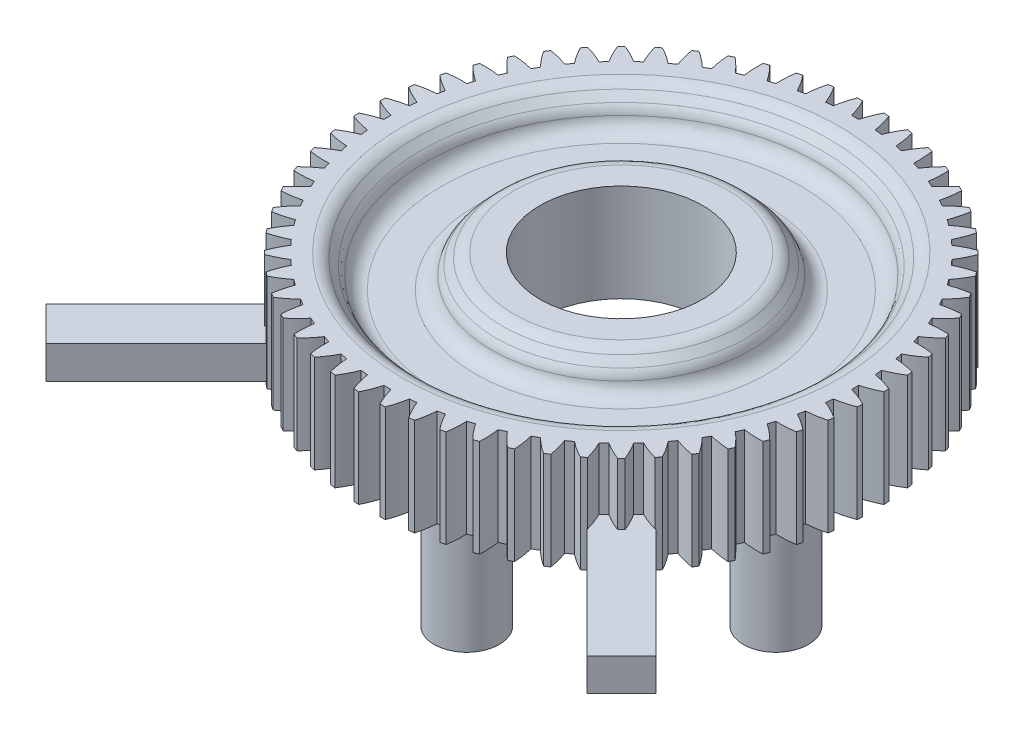
from build123d import *

# Parameters (mm, degrees)
BOSS_EXTRUDE1_DEPTH = 6
SKETCH2_R           = 5
CUT_EXTRUDE2_DEPTH  = 6
SKETCH3_R           = 12
SKETCH3_R_2         = 8
CUT_EXTRUDE3_DEPTH  = 2
CHAMFER1_SIZE       = 1
CHAMFER2_SIZE       = 1
FILLET1_R           = 1
FILLET2_R           = 1
FILLET3_R           = 1
FILLET4_R           = 1
SKETCH4_R           = 2
BOSS_EXTRUDE2_DEPTH = 9.12
FILLET5_R           = 1
FILLET6_R           = 1
SKETCH5_R           = 1.1
CUT_EXTRUDE4_DEPTH  = 8
SKETCH6_R           = 1.1
CUT_EXTRUDE5_DEPTH  = 8
SKETCH8_R           = 1.1
CUT_EXTRUDE6_DEPTH  = 8
SKETCH7_R           = 1.1
CUT_EXTRUDE7_DEPTH  = 8
SKETCH10_W          = 3
SKETCH10_H          = 2
BOSS_EXTRUDE3_DEPTH = 20
SKETCH11_W          = 3
SKETCH11_H          = 2
BOSS_EXTRUDE4_DEPTH = 20


with BuildPart() as part:
    # Sketch1 → Boss-Extrude1 (new body)
    with BuildSketch(Plane(origin=(0, 0, 0), x_dir=(1, 0, 0), z_dir=(0, 1, 0))):
        with BuildLine():
            ThreePointArc((-0.214919076, 14.372458517), (-0.404612151, 14.940310942), (-0.649952369, 15.486431825))
            ThreePointArc((-0.649952369, 15.486431825), (-0.811189587, 15.478823388), (-0.97233883, 15.469536266))
            ThreePointArc((-0.97233883, 15.469536266), (-1.159249871, 14.900762055), (-1.288547047, 14.316192059))
            ThreePointArc((-1.288547047, 14.316192059), (-1.502474396, 14.295323323), (-1.716065774, 14.27125803))
            ThreePointArc((-1.716065774, 14.27125803), (-1.964076433, 14.816171375), (-2.265157828, 15.333655514))
            ThreePointArc((-2.265157828, 15.333655514), (-2.424716474, 15.309234879), (-2.584012155, 15.28315395))
            ThreePointArc((-2.584012155, 15.28315395), (-2.710446184, 14.69795802), (-2.777930853, 14.103075124))
            ThreePointArc((-2.777930853, 14.103075124), (-2.988504909, 14.059959212), (-3.198410703, 14.013699372))
            ThreePointArc((-3.198410703, 14.013699372), (-3.502021688, 14.529703452), (-3.855545549, 15.012881184))
            ThreePointArc((-3.855545549, 15.012881184), (-4.011677465, 14.971915907), (-4.167374308, 14.929326919))
            ThreePointArc((-4.167374308, 14.929326919), (-4.231946087, 14.334120799), (-4.236878873, 13.735442665))
            ThreePointArc((-4.236878873, 13.735442665), (-4.441792543, 13.670551965), (-4.645712981, 13.602604411))
            ThreePointArc((-4.645712981, 13.602604411), (-5.001597866, 14.084045777), (-5.403690912, 14.527623304))
            ThreePointArc((-5.403690912, 14.527623304), (-5.554685483, 14.47056221), (-5.705077642, 14.411931778))
            ThreePointArc((-5.705077642, 14.411931778), (-5.707079709, 13.81323667), (-5.649406567, 13.217322541))
            ThreePointArc((-5.649406567, 13.217322541), (-5.846414773, 13.131368007), (-6.04211566, 13.042477188))
            ThreePointArc((-6.04211566, 13.042477188), (-6.446375297, 13.484081067), (-6.892632113, 13.883198462))
            ThreePointArc((-6.892632113, 13.883198462), (-7.036835011, 13.810666724), (-7.180274757, 13.736637214))
            ThreePointArc((-7.180274757, 13.736637214), (-7.119685177, 13.141012548), (-7.000037986, 12.554391384))
            ThreePointArc((-7.000037986, 12.554391384), (-7.186982265, 12.448314753), (-7.372319462, 12.339454574))
            ThreePointArc((-7.372319462, 12.339454574), (-7.820524697, 12.736382662), (-8.306055999, 13.086667111))
            ThreePointArc((-8.306055999, 13.086667111), (-8.441887308, 12.999459402), (-8.576803085, 12.910841898))
            ThreePointArc((-8.576803085, 12.910841898), (-8.45428569, 12.324813461), (-8.27397533, 11.753912406))
            ThreePointArc((-8.27397533, 11.753912406), (-8.448807482, 11.628875876), (-8.621750395, 11.501239032))
            ThreePointArc((-8.621750395, 11.501239032), (-9.108990598, 11.849142503), (-9.628476804, 12.146756216))
            ThreePointArc((-9.628476804, 12.146756216), (-9.754448327, 12.045828002), (-9.879361969, 11.943593414))
            ThreePointArc((-9.879361969, 11.943593414), (-9.696259085, 11.373581858), (-9.457261075, 10.824655824))
            ThreePointArc((-9.457261075, 10.824655824), (-9.618065601, 10.682029321), (-9.776719431, 10.537014227))
            ThreePointArc((-9.776719431, 10.537014227), (-10.297656297, 10.832081377), (-10.845405807, 11.073763636))
            ThreePointArc((-10.845405807, 11.073763636), (-10.960137374, 10.960220708), (-11.073680302, 10.845489141))
            ThreePointArc((-11.073680302, 10.845489141), (-10.831998043, 10.297739631), (-10.536930893, 9.776802765))
            ThreePointArc((-10.536930893, 9.776802765), (-10.681945987, 9.618148935), (-10.82457249, 9.457344409))
            ThreePointArc((-10.82457249, 9.457344409), (-11.373498524, 9.696342419), (-11.94351008, 9.879445303))
            ThreePointArc((-11.94351008, 9.879445303), (-12.045744668, 9.754531661), (-12.146672882, 9.628560137))
            ThreePointArc((-12.146672882, 9.628560137), (-11.849059169, 9.109073931), (-11.501155698, 8.621833728))
            ThreePointArc((-11.501155698, 8.621833728), (-11.628792543, 8.448890816), (-11.753829073, 8.274058664))
            ThreePointArc((-11.753829073, 8.274058664), (-12.324730128, 8.454369024), (-12.910758564, 8.576886419))
            ThreePointArc((-12.910758564, 8.576886419), (-12.999376069, 8.441970642), (-13.086583777, 8.306139333))
            ThreePointArc((-13.086583777, 8.306139333), (-12.736299329, 7.820608031), (-12.33937124, 7.372402796))
            ThreePointArc((-12.33937124, 7.372402796), (-12.448231419, 7.187065599), (-12.55430805, 7.00012132))
            ThreePointArc((-12.55430805, 7.00012132), (-13.140929214, 7.119768511), (-13.73655388, 7.180358091))
            ThreePointArc((-13.73655388, 7.180358091), (-13.81058339, 7.036918345), (-13.883115128, 6.892715447))
            ThreePointArc((-13.883115128, 6.892715447), (-13.483997733, 6.446458631), (-13.042393854, 6.042198994))
            ThreePointArc((-13.042393854, 6.042198994), (-13.131284674, 5.846498107), (-13.217239207, 5.649489901))
            ThreePointArc((-13.217239207, 5.649489901), (-13.813153336, 5.707163043), (-14.411848444, 5.705160976))
            ThreePointArc((-14.411848444, 5.705160976), (-14.470478876, 5.554768817), (-14.52753997, 5.403774246))
            ThreePointArc((-14.52753997, 5.403774246), (-14.083962443, 5.0016812), (-13.602521077, 4.645796314))
            ThreePointArc((-13.602521077, 4.645796314), (-13.670468631, 4.441875876), (-13.735359331, 4.236962207))
            ThreePointArc((-13.735359331, 4.236962207), (-14.334037465, 4.232029421), (-14.929243585, 4.167457642))
            ThreePointArc((-14.929243585, 4.167457642), (-14.971832573, 4.011760798), (-15.01279785, 3.855628883))
            ThreePointArc((-15.01279785, 3.855628883), (-14.529620118, 3.502105022), (-14.013616039, 3.198494037))
            ThreePointArc((-14.013616039, 3.198494037), (-14.059875878, 2.988588243), (-14.10299179, 2.778014187))
            ThreePointArc((-14.10299179, 2.778014187), (-14.697874686, 2.710529518), (-15.283070616, 2.584095489))
            ThreePointArc((-15.283070616, 2.584095489), (-15.309151545, 2.424799807), (-15.33357218, 2.265241161))
            ThreePointArc((-15.33357218, 2.265241161), (-14.816088041, 1.964159767), (-14.271174696, 1.716149108))
            ThreePointArc((-14.271174696, 1.716149108), (-14.295239989, 1.50255773), (-14.316108725, 1.288630381))
            ThreePointArc((-14.316108725, 1.288630381), (-14.900678721, 1.159333205), (-15.469452932, 0.972422163))
            ThreePointArc((-15.469452932, 0.972422163), (-15.478740054, 0.811272921), (-15.486348491, 0.650035702))
            ThreePointArc((-15.486348491, 0.650035702), (-14.940227609, 0.404695485), (-14.372375183, 0.215002409))
            ThreePointArc((-14.372375183, 0.215002409), (-14.373982265, 6.5599e-05), (-14.372375183, -0.214871211))
            ThreePointArc((-14.372375183, -0.214871211), (-14.940227609, -0.404564286), (-15.486348491, -0.649904504))
            ThreePointArc((-15.486348491, -0.649904504), (-15.478740054, -0.811141722), (-15.469452932, -0.972290965))
            ThreePointArc((-15.469452932, -0.972290965), (-14.900678721, -1.159202007), (-14.316108725, -1.288499182))
            ThreePointArc((-14.316108725, -1.288499182), (-14.295239989, -1.502426532), (-14.271174696, -1.71601791))
            ThreePointArc((-14.271174696, -1.71601791), (-14.816088041, -1.964028568), (-15.33357218, -2.265109963))
            ThreePointArc((-15.33357218, -2.265109963), (-15.309151545, -2.424668609), (-15.283070616, -2.58396429))
            ThreePointArc((-15.283070616, -2.58396429), (-14.697874686, -2.710398319), (-14.10299179, -2.777882988))
            ThreePointArc((-14.10299179, -2.777882988), (-14.059875878, -2.988457045), (-14.013616039, -3.198362838))
            ThreePointArc((-14.013616039, -3.198362838), (-14.529620118, -3.501973823), (-15.01279785, -3.855497684))
            ThreePointArc((-15.01279785, -3.855497684), (-14.971832573, -4.0116296), (-14.929243585, -4.167326443))
            ThreePointArc((-14.929243585, -4.167326443), (-14.334037465, -4.231898222), (-13.735359331, -4.236831008))
            ThreePointArc((-13.735359331, -4.236831008), (-13.670468631, -4.441744678), (-13.602521077, -4.645665116))
            ThreePointArc((-13.602521077, -4.645665116), (-14.083962443, -5.001550001), (-14.52753997, -5.403643047))
            ThreePointArc((-14.52753997, -5.403643047), (-14.470478876, -5.554637619), (-14.411848444, -5.705029777))
            ThreePointArc((-14.411848444, -5.705029777), (-13.813153336, -5.707031844), (-13.217239207, -5.649358702))
            ThreePointArc((-13.217239207, -5.649358702), (-13.131284674, -5.846366908), (-13.042393854, -6.042067795))
            ThreePointArc((-13.042393854, -6.042067795), (-13.483997733, -6.446327432), (-13.883115128, -6.892584248))
            ThreePointArc((-13.883115128, -6.892584248), (-13.81058339, -7.036787147), (-13.73655388, -7.180226892))
            ThreePointArc((-13.73655388, -7.180226892), (-13.140929214, -7.119637312), (-12.55430805, -6.999990121))
            ThreePointArc((-12.55430805, -6.999990121), (-12.448231419, -7.186934401), (-12.33937124, -7.372271597))
            ThreePointArc((-12.33937124, -7.372271597), (-12.736299329, -7.820476832), (-13.086583777, -8.306008134))
            ThreePointArc((-13.086583777, -8.306008134), (-12.999376069, -8.441839443), (-12.910758564, -8.57675522))
            ThreePointArc((-12.910758564, -8.57675522), (-12.324730128, -8.454237825), (-11.753829073, -8.273927465))
            ThreePointArc((-11.753829073, -8.273927465), (-11.628792543, -8.448759617), (-11.501155698, -8.62170253))
            ThreePointArc((-11.501155698, -8.62170253), (-11.849059169, -9.108942733), (-12.146672882, -9.628428939))
            ThreePointArc((-12.146672882, -9.628428939), (-12.045744668, -9.754400462), (-11.943510081, -9.879314104))
            ThreePointArc((-11.943510081, -9.879314104), (-11.373498524, -9.696211221), (-10.82457249, -9.45721321))
            ThreePointArc((-10.82457249, -9.45721321), (-10.681945987, -9.618017736), (-10.536930893, -9.776671567))
            ThreePointArc((-10.536930893, -9.776671567), (-10.831998043, -10.297608432), (-11.073680302, -10.845357942))
            ThreePointArc((-11.073680302, -10.845357942), (-10.960137374, -10.960089509), (-10.845405807, -11.073632437))
            ThreePointArc((-10.845405807, -11.073632437), (-10.297656297, -10.831950178), (-9.776719431, -10.536883029))
            ThreePointArc((-9.776719431, -10.536883029), (-9.618065601, -10.681898122), (-9.457261075, -10.824524625))
            ThreePointArc((-9.457261075, -10.824524625), (-9.696259085, -11.373450659), (-9.879361969, -11.943462216))
            ThreePointArc((-9.879361969, -11.943462216), (-9.754448327, -12.045696803), (-9.628476804, -12.146625017))
            ThreePointArc((-9.628476804, -12.146625017), (-9.108990598, -11.849011304), (-8.621750395, -11.501107833))
            ThreePointArc((-8.621750395, -11.501107833), (-8.448807482, -11.628744678), (-8.27397533, -11.753781208))
            ThreePointArc((-8.27397533, -11.753781208), (-8.45428569, -12.324682263), (-8.576803085, -12.910710699))
            ThreePointArc((-8.576803085, -12.910710699), (-8.441887308, -12.999328204), (-8.306055999, -13.086535913))
            ThreePointArc((-8.306055999, -13.086535913), (-7.820524697, -12.736251464), (-7.372319462, -12.339323375))
            ThreePointArc((-7.372319462, -12.339323375), (-7.186982265, -12.448183555), (-7.000037986, -12.554260185))
            ThreePointArc((-7.000037986, -12.554260185), (-7.119685177, -13.140881349), (-7.180274757, -13.736506016))
            ThreePointArc((-7.180274757, -13.736506016), (-7.036835011, -13.810535526), (-6.892632113, -13.883067263))
            ThreePointArc((-6.892632113, -13.883067263), (-6.446375297, -13.483949869), (-6.04211566, -13.042345989))
            ThreePointArc((-6.04211566, -13.042345989), (-5.846414773, -13.131236809), (-5.649406567, -13.217191342))
            ThreePointArc((-5.649406567, -13.217191342), (-5.707079709, -13.813105471), (-5.705077642, -14.411800579))
            ThreePointArc((-5.705077642, -14.411800579), (-5.554685483, -14.470431011), (-5.403690912, -14.527492105))
            ThreePointArc((-5.403690912, -14.527492105), (-5.001597866, -14.083914578), (-4.645712981, -13.602473212))
            ThreePointArc((-4.645712981, -13.602473212), (-4.441792543, -13.670420766), (-4.236878873, -13.735311466))
            ThreePointArc((-4.236878873, -13.735311466), (-4.231946087, -14.3339896), (-4.167374308, -14.929195721))
            ThreePointArc((-4.167374308, -14.929195721), (-4.011677465, -14.971784708), (-3.855545549, -15.012749985))
            ThreePointArc((-3.855545549, -15.012749985), (-3.502021688, -14.529572254), (-3.198410703, -14.013568174))
            ThreePointArc((-3.198410703, -14.013568174), (-2.988504909, -14.059828014), (-2.777930853, -14.102943925))
            ThreePointArc((-2.777930853, -14.102943925), (-2.710446184, -14.697826821), (-2.584012155, -15.283022751))
            ThreePointArc((-2.584012155, -15.283022751), (-2.424716474, -15.30910368), (-2.265157828, -15.333524315))
            ThreePointArc((-2.265157828, -15.333524315), (-1.964076433, -14.816040176), (-1.716065774, -14.271126831))
            ThreePointArc((-1.716065774, -14.271126831), (-1.502474396, -14.295192125), (-1.288547047, -14.31606086))
            ThreePointArc((-1.288547047, -14.31606086), (-1.159249871, -14.900630857), (-0.97233883, -15.469405068))
            ThreePointArc((-0.97233883, -15.469405068), (-0.811189587, -15.478692189), (-0.649952369, -15.486300626))
            ThreePointArc((-0.649952369, -15.486300626), (-0.404612151, -14.940179744), (-0.214919076, -14.372327318))
            ThreePointArc((-0.214919076, -14.372327318), (1.7735e-05, -14.373934401), (0.214954545, -14.372327318))
            ThreePointArc((0.214954545, -14.372327318), (0.40464762, -14.940179744), (0.649987838, -15.486300626))
            ThreePointArc((0.649987838, -15.486300626), (0.811225056, -15.478692189), (0.972374299, -15.469405068))
            ThreePointArc((0.972374299, -15.469405068), (1.15928534, -14.900630857), (1.288582516, -14.31606086))
            ThreePointArc((1.288582516, -14.31606086), (1.502509866, -14.295192125), (1.716101244, -14.271126831))
            ThreePointArc((1.716101244, -14.271126831), (1.964111902, -14.816040176), (2.265193297, -15.333524315))
            ThreePointArc((2.265193297, -15.333524315), (2.424751943, -15.30910368), (2.584047624, -15.283022751))
            ThreePointArc((2.584047624, -15.283022751), (2.710481653, -14.697826821), (2.777966322, -14.102943925))
            ThreePointArc((2.777966322, -14.102943925), (2.988540378, -14.059828014), (3.198446172, -14.013568174))
            ThreePointArc((3.198446172, -14.013568174), (3.502057157, -14.529572254), (3.855581018, -15.012749985))
            ThreePointArc((3.855581018, -15.012749985), (4.011712934, -14.971784708), (4.167409777, -14.929195721))
            ThreePointArc((4.167409777, -14.929195721), (4.231981556, -14.3339896), (4.236914342, -13.735311466))
            ThreePointArc((4.236914342, -13.735311466), (4.441828012, -13.670420766), (4.64574845, -13.602473212))
            ThreePointArc((4.64574845, -13.602473212), (5.001633335, -14.083914578), (5.403726381, -14.527492105))
            ThreePointArc((5.403726381, -14.527492105), (5.554720953, -14.470431011), (5.705113111, -14.411800579))
            ThreePointArc((5.705113111, -14.411800579), (5.707115178, -13.813105471), (5.649442036, -13.217191342))
            ThreePointArc((5.649442036, -13.217191342), (5.846450242, -13.131236809), (6.042151129, -13.042345989))
            ThreePointArc((6.042151129, -13.042345989), (6.446410766, -13.483949869), (6.892667582, -13.883067263))
            ThreePointArc((6.892667582, -13.883067263), (7.036870481, -13.810535526), (7.180310226, -13.736506016))
            ThreePointArc((7.180310226, -13.736506016), (7.119720646, -13.140881349), (7.000073455, -12.554260185))
            ThreePointArc((7.000073455, -12.554260185), (7.187017735, -12.448183555), (7.372354931, -12.339323375))
            ThreePointArc((7.372354931, -12.339323375), (7.820560166, -12.736251464), (8.306091468, -13.086535913))
            ThreePointArc((8.306091468, -13.086535913), (8.441922777, -12.999328204), (8.576838554, -12.910710699))
            ThreePointArc((8.576838554, -12.910710699), (8.454321159, -12.324682263), (8.274010799, -11.753781208))
            ThreePointArc((8.274010799, -11.753781208), (8.448842951, -11.628744678), (8.621785864, -11.501107833))
            ThreePointArc((8.621785864, -11.501107833), (9.109026067, -11.849011304), (9.628512273, -12.146625017))
            ThreePointArc((9.628512273, -12.146625017), (9.754483796, -12.045696803), (9.879397438, -11.943462216))
            ThreePointArc((9.879397438, -11.943462216), (9.696294554, -11.373450659), (9.457296544, -10.824524625))
            ThreePointArc((9.457296544, -10.824524625), (9.61810107, -10.681898122), (9.7767549, -10.536883029))
            ThreePointArc((9.7767549, -10.536883029), (10.297691766, -10.831950178), (10.845441276, -11.073632437))
            ThreePointArc((10.845441276, -11.073632437), (10.960172843, -10.960089509), (11.073715771, -10.845357942))
            ThreePointArc((11.073715771, -10.845357942), (10.832033512, -10.297608432), (10.536966363, -9.776671567))
            ThreePointArc((10.536966363, -9.776671567), (10.681981456, -9.618017736), (10.824607959, -9.45721321))
            ThreePointArc((10.824607959, -9.45721321), (11.373533993, -9.696211221), (11.94354555, -9.879314104))
            ThreePointArc((11.94354555, -9.879314104), (12.045780137, -9.754400462), (12.146708351, -9.628428939))
            ThreePointArc((12.146708351, -9.628428939), (11.849094638, -9.108942733), (11.501191167, -8.62170253))
            ThreePointArc((11.501191167, -8.62170253), (11.628828012, -8.448759617), (11.753864542, -8.273927465))
            ThreePointArc((11.753864542, -8.273927465), (12.324765597, -8.454237825), (12.910794033, -8.57675522))
            ThreePointArc((12.910794033, -8.57675522), (12.999411538, -8.441839443), (13.086619246, -8.306008134))
            ThreePointArc((13.086619246, -8.306008134), (12.736334798, -7.820476832), (12.339406709, -7.372271597))
            ThreePointArc((12.339406709, -7.372271597), (12.448266889, -7.186934401), (12.554343519, -6.999990121))
            ThreePointArc((12.554343519, -6.999990121), (13.140964683, -7.119637312), (13.73658935, -7.180226892))
            ThreePointArc((13.73658935, -7.180226892), (13.810618859, -7.036787147), (13.883150597, -6.892584248))
            ThreePointArc((13.883150597, -6.892584248), (13.484033202, -6.446327432), (13.042429323, -6.042067795))
            ThreePointArc((13.042429323, -6.042067795), (13.131320143, -5.846366908), (13.217274676, -5.649358702))
            ThreePointArc((13.217274676, -5.649358702), (13.813188805, -5.707031844), (14.411883913, -5.705029777))
            ThreePointArc((14.411883913, -5.705029777), (14.470514345, -5.554637619), (14.527575439, -5.403643047))
            ThreePointArc((14.527575439, -5.403643047), (14.083997912, -5.001550001), (13.602556546, -4.645665116))
            ThreePointArc((13.602556546, -4.645665116), (13.6705041, -4.441744678), (13.7353948, -4.236831008))
            ThreePointArc((13.7353948, -4.236831008), (14.334072934, -4.231898222), (14.929279055, -4.167326443))
            ThreePointArc((14.929279055, -4.167326443), (14.971868042, -4.0116296), (15.012833319, -3.855497684))
            ThreePointArc((15.012833319, -3.855497684), (14.529655588, -3.501973823), (14.013651508, -3.198362838))
            ThreePointArc((14.013651508, -3.198362838), (14.059911348, -2.988457045), (14.103027259, -2.777882988))
            ThreePointArc((14.103027259, -2.777882988), (14.697910155, -2.710398319), (15.283106085, -2.58396429))
            ThreePointArc((15.283106085, -2.58396429), (15.309187014, -2.424668609), (15.333607649, -2.265109963))
            ThreePointArc((15.333607649, -2.265109963), (14.81612351, -1.964028568), (14.271210165, -1.71601791))
            ThreePointArc((14.271210165, -1.71601791), (14.295275459, -1.502426532), (14.316144194, -1.288499182))
            ThreePointArc((14.316144194, -1.288499182), (14.900714191, -1.159202007), (15.469488401, -0.972290965))
            ThreePointArc((15.469488401, -0.972290965), (15.478775523, -0.811141722), (15.48638396, -0.649904504))
            ThreePointArc((15.48638396, -0.649904504), (14.940263078, -0.404564286), (14.372410652, -0.214871211))
            ThreePointArc((14.372410652, -0.214871211), (14.374017735, 6.5599e-05), (14.372410652, 0.215002409))
            ThreePointArc((14.372410652, 0.215002409), (14.940263078, 0.404695485), (15.48638396, 0.650035702))
            ThreePointArc((15.48638396, 0.650035702), (15.478775523, 0.811272921), (15.469488401, 0.972422163))
            ThreePointArc((15.469488401, 0.972422163), (14.900714191, 1.159333205), (14.316144194, 1.288630381))
            ThreePointArc((14.316144194, 1.288630381), (14.295275459, 1.50255773), (14.271210165, 1.716149108))
            ThreePointArc((14.271210165, 1.716149108), (14.81612351, 1.964159767), (15.333607649, 2.265241161))
            ThreePointArc((15.333607649, 2.265241161), (15.309187014, 2.424799807), (15.283106085, 2.584095489))
            ThreePointArc((15.283106085, 2.584095489), (14.697910155, 2.710529518), (14.103027259, 2.778014187))
            ThreePointArc((14.103027259, 2.778014187), (14.059911348, 2.988588243), (14.013651508, 3.198494037))
            ThreePointArc((14.013651508, 3.198494037), (14.529655588, 3.502105022), (15.012833319, 3.855628883))
            ThreePointArc((15.012833319, 3.855628883), (14.971868042, 4.011760798), (14.929279055, 4.167457642))
            ThreePointArc((14.929279055, 4.167457642), (14.334072934, 4.232029421), (13.7353948, 4.236962207))
            ThreePointArc((13.7353948, 4.236962207), (13.6705041, 4.441875876), (13.602556546, 4.645796314))
            ThreePointArc((13.602556546, 4.645796314), (14.083997912, 5.0016812), (14.527575439, 5.403774246))
            ThreePointArc((14.527575439, 5.403774246), (14.470514345, 5.554768817), (14.411883913, 5.705160976))
            ThreePointArc((14.411883913, 5.705160976), (13.813188805, 5.707163043), (13.217274676, 5.649489901))
            ThreePointArc((13.217274676, 5.649489901), (13.131320143, 5.846498107), (13.042429323, 6.042198994))
            ThreePointArc((13.042429323, 6.042198994), (13.484033202, 6.446458631), (13.883150597, 6.892715447))
            ThreePointArc((13.883150597, 6.892715447), (13.810618859, 7.036918345), (13.73658935, 7.180358091))
            ThreePointArc((13.73658935, 7.180358091), (13.140964683, 7.119768511), (12.554343519, 7.00012132))
            ThreePointArc((12.554343519, 7.00012132), (12.448266889, 7.187065599), (12.339406709, 7.372402796))
            ThreePointArc((12.339406709, 7.372402796), (12.736334798, 7.820608031), (13.086619246, 8.306139333))
            ThreePointArc((13.086619246, 8.306139333), (12.999411538, 8.441970642), (12.910794033, 8.576886419))
            ThreePointArc((12.910794033, 8.576886419), (12.324765597, 8.454369024), (11.753864542, 8.274058664))
            ThreePointArc((11.753864542, 8.274058664), (11.628828012, 8.448890816), (11.501191167, 8.621833728))
            ThreePointArc((11.501191167, 8.621833728), (11.849094638, 9.109073931), (12.146708351, 9.628560137))
            ThreePointArc((12.146708351, 9.628560137), (12.045780137, 9.754531661), (11.94354555, 9.879445303))
            ThreePointArc((11.94354555, 9.879445303), (11.373533993, 9.696342419), (10.824607959, 9.457344409))
            ThreePointArc((10.824607959, 9.457344409), (10.681981456, 9.618148935), (10.536966363, 9.776802765))
            ThreePointArc((10.536966363, 9.776802765), (10.832033512, 10.297739631), (11.073715771, 10.845489141))
            ThreePointArc((11.073715771, 10.845489141), (10.960172843, 10.960220708), (10.845441276, 11.073763636))
            ThreePointArc((10.845441276, 11.073763636), (10.297691766, 10.832081377), (9.7767549, 10.537014227))
            ThreePointArc((9.7767549, 10.537014227), (9.61810107, 10.682029321), (9.457296544, 10.824655824))
            ThreePointArc((9.457296544, 10.824655824), (9.696294554, 11.373581858), (9.879397438, 11.943593414))
            ThreePointArc((9.879397438, 11.943593414), (9.754483796, 12.045828002), (9.628512273, 12.146756216))
            ThreePointArc((9.628512273, 12.146756216), (9.109026067, 11.849142503), (8.621785864, 11.501239032))
            ThreePointArc((8.621785864, 11.501239032), (8.448842951, 11.628875876), (8.274010799, 11.753912406))
            ThreePointArc((8.274010799, 11.753912406), (8.454321159, 12.324813461), (8.576838554, 12.910841898))
            ThreePointArc((8.576838554, 12.910841898), (8.441922777, 12.999459402), (8.306091468, 13.086667111))
            ThreePointArc((8.306091468, 13.086667111), (7.820560166, 12.736382662), (7.372354931, 12.339454574))
            ThreePointArc((7.372354931, 12.339454574), (7.187017735, 12.448314753), (7.000073455, 12.554391384))
            ThreePointArc((7.000073455, 12.554391384), (7.119720646, 13.141012548), (7.180310226, 13.736637214))
            ThreePointArc((7.180310226, 13.736637214), (7.036870481, 13.810666724), (6.892667582, 13.883198462))
            ThreePointArc((6.892667582, 13.883198462), (6.446410766, 13.484081067), (6.042151129, 13.042477188))
            ThreePointArc((6.042151129, 13.042477188), (5.846450242, 13.131368007), (5.649442036, 13.217322541))
            ThreePointArc((5.649442036, 13.217322541), (5.707115178, 13.81323667), (5.705113111, 14.411931778))
            ThreePointArc((5.705113111, 14.411931778), (5.554720953, 14.47056221), (5.403726381, 14.527623304))
            ThreePointArc((5.403726381, 14.527623304), (5.001633335, 14.084045777), (4.64574845, 13.602604411))
            ThreePointArc((4.64574845, 13.602604411), (4.441828012, 13.670551965), (4.236914342, 13.735442665))
            ThreePointArc((4.236914342, 13.735442665), (4.231981556, 14.334120799), (4.167409777, 14.929326919))
            ThreePointArc((4.167409777, 14.929326919), (4.011712934, 14.971915907), (3.855581018, 15.012881184))
            ThreePointArc((3.855581018, 15.012881184), (3.502057157, 14.529703452), (3.198446172, 14.013699372))
            ThreePointArc((3.198446172, 14.013699372), (2.988540378, 14.059959212), (2.777966322, 14.103075124))
            ThreePointArc((2.777966322, 14.103075124), (2.710481653, 14.69795802), (2.584047624, 15.28315395))
            ThreePointArc((2.584047624, 15.28315395), (2.424751943, 15.309234879), (2.265193297, 15.333655514))
            ThreePointArc((2.265193297, 15.333655514), (1.964111902, 14.816171375), (1.716101244, 14.27125803))
            ThreePointArc((1.716101244, 14.27125803), (1.502509866, 14.295323323), (1.288582516, 14.316192059))
            ThreePointArc((1.288582516, 14.316192059), (1.15928534, 14.900762055), (0.972374299, 15.469536266))
            ThreePointArc((0.972374299, 15.469536266), (0.811225056, 15.478823388), (0.649987838, 15.486431825))
            ThreePointArc((0.649987838, 15.486431825), (0.40464762, 14.940310942), (0.214954545, 14.372458517))
            ThreePointArc((0.214954545, 14.372458517), (1.7735e-05, 14.374065599), (-0.214919076, 14.372458517))
        make_face()
    extrude(amount=BOSS_EXTRUDE1_DEPTH)

    # Sketch2 → Cut-Extrude2 (cut)
    with BuildSketch(Plane(origin=(0, 6, 0), x_dir=(1, 0, 0), z_dir=(0, 1, 0))):
        Circle(SKETCH2_R)
    extrude(amount=-CUT_EXTRUDE2_DEPTH, mode=Mode.SUBTRACT)

    # Sketch3 → Cut-Extrude3 (cut)
    with BuildSketch(Plane(origin=(0, 6, 0), x_dir=(1, 0, 0), z_dir=(0, 1, 0))):
        Circle(SKETCH3_R)
        Circle(SKETCH3_R_2, mode=Mode.SUBTRACT)
    extrude(amount=-CUT_EXTRUDE3_DEPTH, mode=Mode.SUBTRACT)

    # Chamfer1
    chamfer1_edges = [part.edges().sort_by_distance(p)[0] for p in [
        (-12, 6, 0),
    ]]
    chamfer(chamfer1_edges, length=CHAMFER1_SIZE)

    # Chamfer2
    chamfer2_edges = [part.edges().sort_by_distance(p)[0] for p in [
        (-8, 6, 0),
    ]]
    chamfer(chamfer2_edges, length=CHAMFER2_SIZE)

    # Fillet1
    fillet1_edges = [part.edges().sort_by_distance(p)[0] for p in [
        (-13, 6, 0),
    ]]
    fillet(fillet1_edges, radius=FILLET1_R)

    # Fillet2
    fillet2_edges = [part.edges().sort_by_distance(p)[0] for p in [
        (-12, 5, 0),
    ]]
    fillet(fillet2_edges, radius=FILLET2_R)

    # Fillet3
    fillet3_edges = [part.edges().sort_by_distance(p)[0] for p in [
        (-7, 6, 0),
    ]]
    fillet(fillet3_edges, radius=FILLET3_R)

    # Fillet4
    fillet4_edges = [part.edges().sort_by_distance(p)[0] for p in [
        (-8, 5, 0),
    ]]
    fillet(fillet4_edges, radius=FILLET4_R)

    # Sketch4 → Boss-Extrude2 (add)
    with BuildSketch(Plane.XZ):
        with Locations((-9.5, 0)):
            Circle(SKETCH4_R)
        with Locations((0, -9.5)):
            Circle(SKETCH4_R)
        with Locations((9.5, 0)):
            Circle(SKETCH4_R)
        with Locations((0, 9.5)):
            Circle(SKETCH4_R)
    extrude(amount=BOSS_EXTRUDE2_DEPTH)

    # Fillet5
    fillet5_edges = [part.edges().sort_by_distance(p)[0] for p in [
        (-12, 4, 0),
    ]]
    fillet(fillet5_edges, radius=FILLET5_R)

    # Fillet6
    fillet6_edges = [part.edges().sort_by_distance(p)[0] for p in [
        (-8, 4, 0),
    ]]
    fillet(fillet6_edges, radius=FILLET6_R)

    # Sketch5 → Cut-Extrude4 (cut)
    with BuildSketch(Plane.XZ.offset(9.12)):
        with Locations((-9.5, 0)):
            Circle(SKETCH5_R)
    extrude(amount=-CUT_EXTRUDE4_DEPTH, mode=Mode.SUBTRACT)

    # Sketch6 → Cut-Extrude5 (cut)
    with BuildSketch(Plane.XZ.offset(9.12)):
        with Locations((0, 9.5)):
            Circle(SKETCH6_R)
    extrude(amount=-CUT_EXTRUDE5_DEPTH, mode=Mode.SUBTRACT)

    # Sketch8 → Cut-Extrude6 (cut)
    with BuildSketch(Plane.XZ.offset(9.12)):
        with Locations((9.5, 0)):
            Circle(SKETCH8_R)
    extrude(amount=-CUT_EXTRUDE6_DEPTH, mode=Mode.SUBTRACT)

    # Sketch7 → Cut-Extrude7 (cut)
    with BuildSketch(Plane.XZ.offset(9.12)):
        with Locations((0, -9.5)):
            Circle(SKETCH7_R)
    extrude(amount=-CUT_EXTRUDE7_DEPTH, mode=Mode.SUBTRACT)

    # Sketch10 → Boss-Extrude3 (add)
    with BuildSketch(Plane(origin=(-3.535533906, 0, 3.535533906), x_dir=(-0.707106781, 0, -0.707106781), z_dir=(0.707106781, 0, -0.707106781))):
        with Locations((0, 1.2)):
            Rectangle(SKETCH10_W, SKETCH10_H)
    extrude(amount=-BOSS_EXTRUDE3_DEPTH)

    # Sketch11 → Boss-Extrude4 (add)
    with BuildSketch(Plane(origin=(3.535533906, 0, 3.535533906), x_dir=(-0.707106781, 0, 0.707106781), z_dir=(-0.707106781, 0, -0.707106781))):
        with Locations((0, 1.2)):
            Rectangle(SKETCH11_W, SKETCH11_H)
    extrude(amount=-BOSS_EXTRUDE4_DEPTH)


solid = part.part
